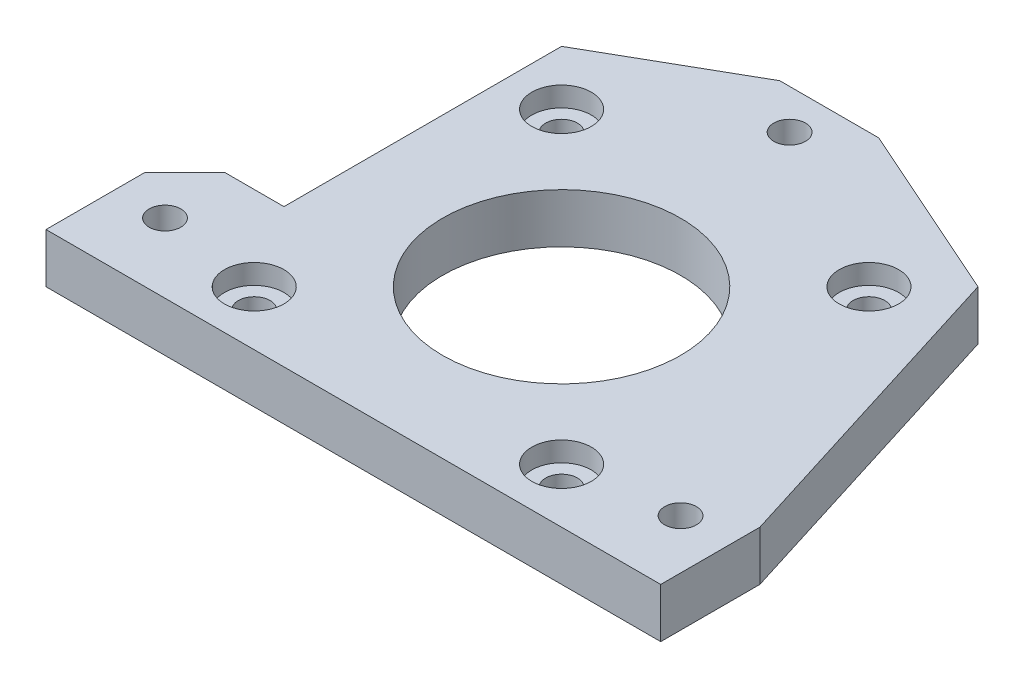
from build123d import *

# Parameters (mm, degrees)
SKETCH1_W           = 42
SKETCH1_H           = 42
SKETCH1_R           = 12
SKETCH1_R_2         = 1.6
BOSS_EXTRUDE1_DEPTH = 5
SKETCH3_R           = 3
CUT_EXTRUDE1_DEPTH  = 2


with BuildPart() as part:
    # Sketch1 → Boss-Extrude1 (new body)
    with BuildSketch(Plane(origin=(0, 0, 0), x_dir=(1, 0, 0), z_dir=(0, 1, 0))):
        Rectangle(SKETCH1_W, SKETCH1_H)
        Circle(SKETCH1_R, mode=Mode.SUBTRACT)
        with Locations((15.5, 15.5)):
            Circle(SKETCH1_R_2, mode=Mode.SUBTRACT)
        with Locations((-15.5, 15.5)):
            Circle(SKETCH1_R_2, mode=Mode.SUBTRACT)
        with Locations((-15.5, -15.5)):
            Circle(SKETCH1_R_2, mode=Mode.SUBTRACT)
        with Locations((15.5, -15.5)):
            Circle(SKETCH1_R_2, mode=Mode.SUBTRACT)
        Polygon((-31, -21), (-21, -21), (-21, -7), (-27, -7), (-31, -11), align=None)
        with Locations((-26, -14)):
            Circle(SKETCH1_R_2, mode=Mode.SUBTRACT)
        Polygon((21, -7), (21, -21), (31, -21), (31, -11), (27, -7), align=None)
        with Locations((26, -14)):
            Circle(SKETCH1_R_2, mode=Mode.SUBTRACT)
        Polygon((-7, 29), (-11, 21), (7, 21), (3, 29), align=None)
        with Locations((-2, 25)):
            Circle(SKETCH1_R_2, mode=Mode.SUBTRACT)
        Polygon((21, 21), (21, -7), (27, -7), (31, -11), align=None)
        Polygon((-7, 29), (-21, 21), (-11, 21), align=None)
        Polygon((7, 21), (21, 21), (3, 29), align=None)
    extrude(amount=BOSS_EXTRUDE1_DEPTH)

    # Sketch3 → Cut-Extrude1 (cut)
    with BuildSketch(Plane(origin=(0, 5, 0), x_dir=(1, 0, 0), z_dir=(0, 1, 0))):
        with Locations((-15.5, 15.5)):
            Circle(SKETCH3_R)
        with Locations((15.5, 15.5)):
            Circle(SKETCH3_R)
        with Locations((15.5, -15.5)):
            Circle(SKETCH3_R)
        with Locations((-15.5, -15.5)):
            Circle(SKETCH3_R)
    extrude(amount=-CUT_EXTRUDE1_DEPTH, mode=Mode.SUBTRACT)


solid = part.part
